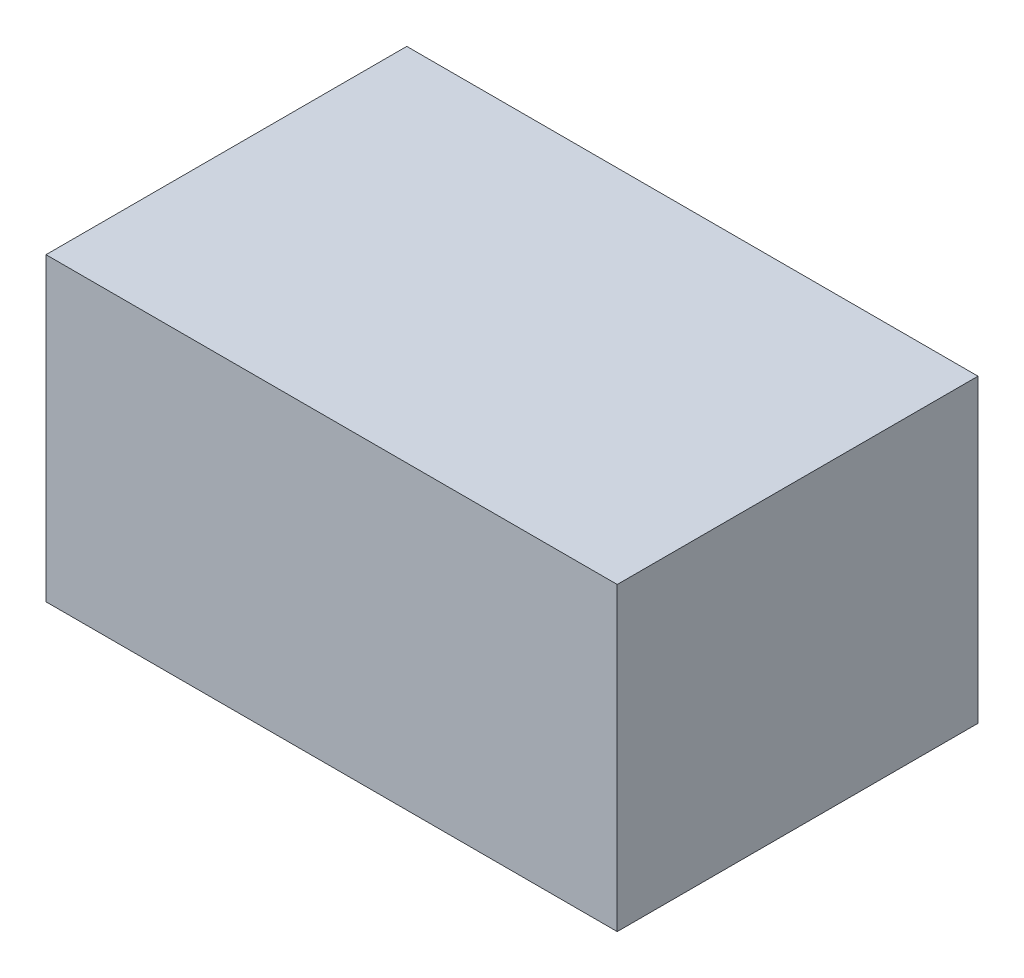
from build123d import *

# Parameters (mm, degrees)
SKETCH1_W           = 475
SKETCH1_H           = 300
BOSS_EXTRUDE1_DEPTH = 250


with BuildPart() as part:
    # Sketch1 → Boss-Extrude1 (new body)
    with BuildSketch(Plane(origin=(0, 0, 0), x_dir=(1, 0, 0), z_dir=(0, 1, 0))):
        with Locations((237.5, 150)):
            Rectangle(SKETCH1_W, SKETCH1_H)
    extrude(amount=BOSS_EXTRUDE1_DEPTH)


solid = part.part
